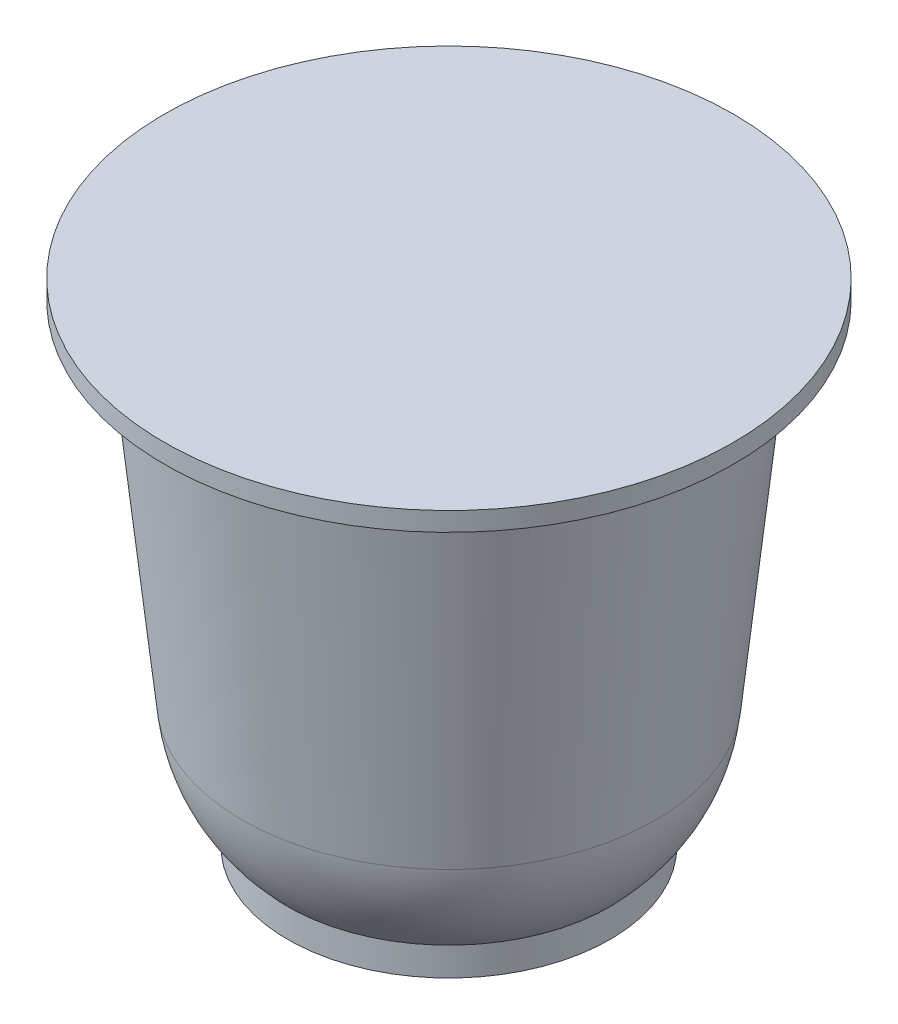
from build123d import *


with BuildPart() as part:
    # Sketch1 → Revolve1 (revolve)
    with BuildSketch(Plane.XY):
        with BuildLine():
            Line((0, 0), (0, 26.3652))
            Line((0, 26.3652), (15.24, 26.3652))
            Line((15.24, 26.3652), (15.24, 25.3492))
            Line((15.24, 25.3492), (13.011421866, 25.3492))
            Line((13.011421866, 25.3492), (11.071462345, 6.757727738))
            ThreePointArc((11.071462345, 6.757727738), (10.291574862, 3.936885962), (8.636, 1.523497331))
            Line((8.636, 1.523497331), (8.636, 0))
            Line((8.636, 0), (0, 0))
        make_face()
    revolve(axis=Axis((0, 0, 0), (0, 1, 0)))


solid = part.part
